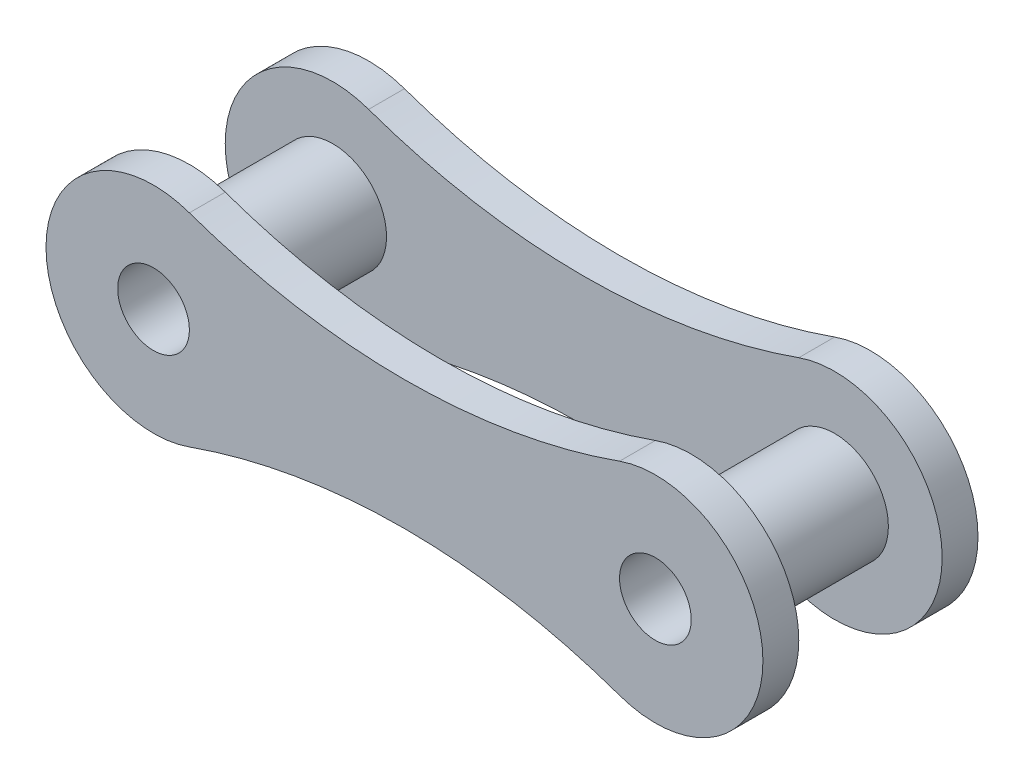
from build123d import *

# Parameters (mm, degrees)
SKETCH1_R           = 1
BOSS_EXTRUDE1_DEPTH = 1
SKETCH2_R           = 1.5
SKETCH2_R_2         = 1
BOSS_EXTRUDE2_DEPTH = 5


with BuildPart() as part:
    # Sketch1 → Boss-Extrude1 (new body)
    with BuildSketch(Plane.XY):
        with BuildLine():
            ThreePointArc((-6, 2.828427125), (-10, 0), (-6, -2.828427125))
            ThreePointArc((-6, -2.828427125), (0, -1.798989873), (6, -2.828427125))
            ThreePointArc((6, -2.828427125), (10, 0), (6, 2.828427125))
            ThreePointArc((6, 2.828427125), (0, 1.798989873), (-6, 2.828427125))
        make_face()
        with Locations((-7, 0)):
            Circle(SKETCH1_R, mode=Mode.SUBTRACT)
        with Locations((7, 0)):
            Circle(SKETCH1_R, mode=Mode.SUBTRACT)
    boss_extrude1 = extrude(amount=BOSS_EXTRUDE1_DEPTH)

    # Sketch2 → Boss-Extrude2 (add)
    with BuildSketch(Plane.XY.offset(1)):
        with Locations((-7, 0)):
            Circle(SKETCH2_R)
        with Locations((-7, 0)):
            Circle(SKETCH2_R_2, mode=Mode.SUBTRACT)
        with Locations((7, 0)):
            Circle(SKETCH2_R)
        with Locations((7, 0)):
            Circle(SKETCH2_R_2, mode=Mode.SUBTRACT)
    extrude(amount=BOSS_EXTRUDE2_DEPTH)

    # Mirror1: Boss-Extrude1 across plane
    add(boss_extrude1.mirror(Plane.XY.offset(3)))


solid = part.part
